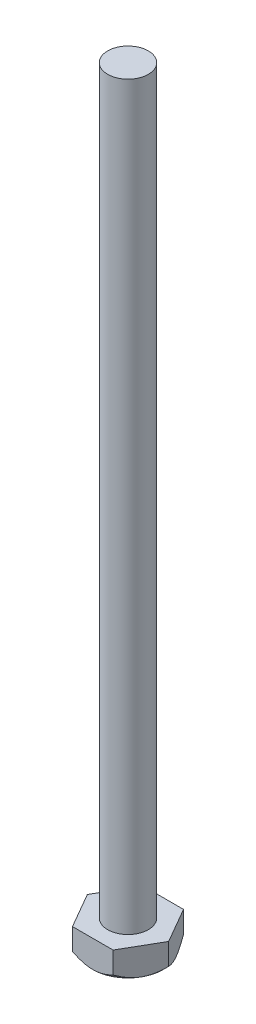
from build123d import *

# Parameters (mm, degrees)
BOSS_EXTRUDE1_DEPTH = 3
SKETCH2_R           = 2.25
BOSS_EXTRUDE2_DEPTH = 82


with BuildPart() as part:
    # Sketch1 → Boss-Extrude1 (new body)
    with BuildSketch(Plane(origin=(0, 0, 0), x_dir=(1, 0, 0), z_dir=(0, 1, 0))):
        Polygon((-4.5, 0), (-2.25, -3.897114317), (2.25, -3.897114317), (4.5, 0), (2.25, 3.897114317), (-2.25, 3.897114317), align=None)
    extrude(amount=BOSS_EXTRUDE1_DEPTH)

    # Sketch2 → Boss-Extrude2 (add)
    with BuildSketch(Plane(origin=(0, 3, 0), x_dir=(1, 0, 0), z_dir=(0, 1, 0))):
        Circle(SKETCH2_R)
    extrude(amount=BOSS_EXTRUDE2_DEPTH)

    # Sketch4 → Cut-Revolve1 (revolve, cut)
    with BuildSketch(Plane(origin=(0, 0, 0), x_dir=(0, 0, -1), z_dir=(1, 0, 0))):
        Polygon((3.897114317, 0), (4.897114317, 1), (4.897114317, 0), align=None)
    revolve(axis=Axis((0, 0, 0), (0, 1, 0)), mode=Mode.SUBTRACT)


solid = part.part
